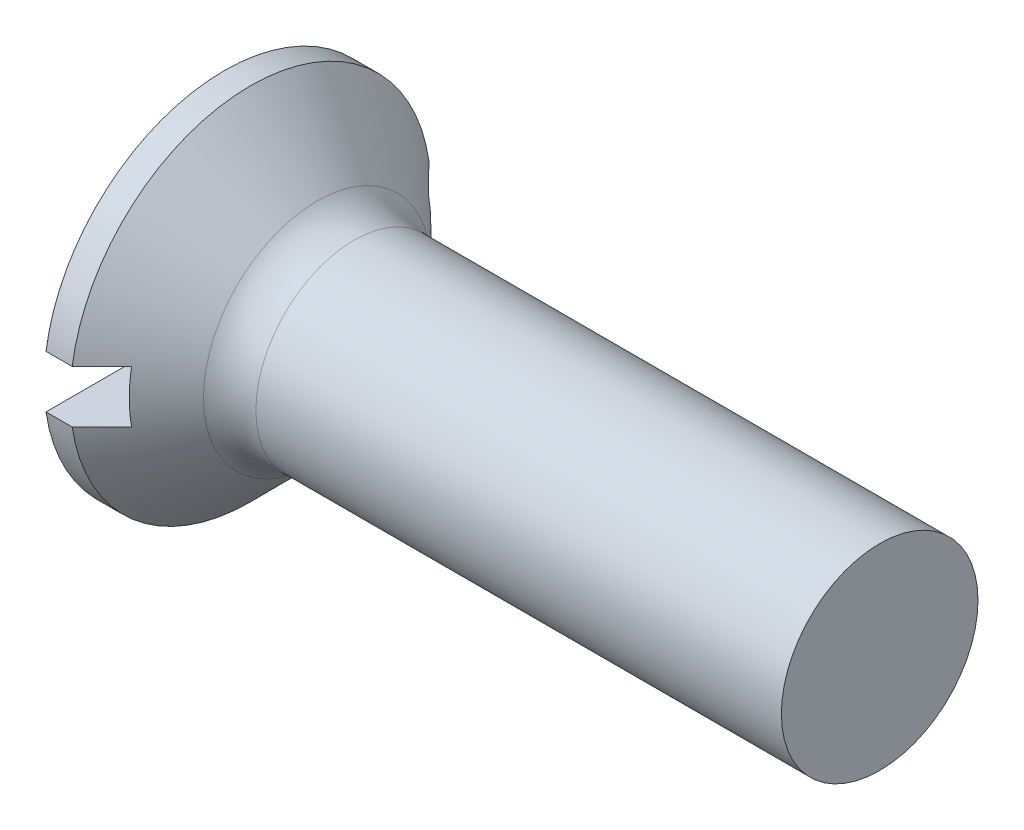
from build123d import *

# Parameters (mm, degrees)
FILLET1_R  = 0.8
SKETCH2_W  = 5.5
SKETCH2_H  = 0.8
SLOT_DEPTH = 0.85


with BuildPart() as part:
    # BodySke → Base-Revolve (revolve)
    with BuildSketch(Plane.XY, mode=Mode.PRIVATE) as base_revolve_sk:
        Polygon((0, 0), (0, 2.75), (0.4, 2.75), (1.65, 1.5), (10, 1.5), (10, 0), align=None)
    revolve(base_revolve_sk.sketch.rotate(Axis((-6.35, 0, 0), (1, 0, 0)), 90), axis=Axis((-6.35, 0, 0), (1, 0, 0)))  # turned: the seam where the file's is

    # Fillet1
    fillet1_edges = [part.edges().sort_by_distance(p)[0] for p in [
        (1.65, 0, -1.5),
    ]]
    fillet(fillet1_edges, radius=FILLET1_R)

    # Sketch2 → Slot (cut)
    with BuildSketch(Plane.ZY):
        Rectangle(SKETCH2_W, SKETCH2_H)
    extrude(amount=-SLOT_DEPTH, mode=Mode.SUBTRACT)


solid = part.part
